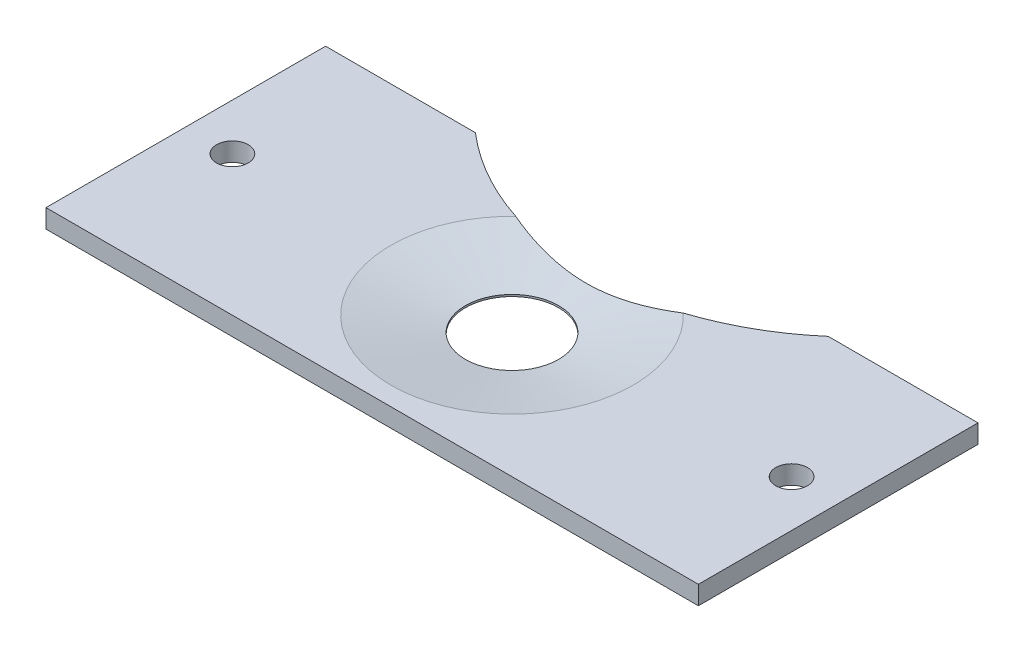
from build123d import *

# Parameters (mm, degrees)
SKETCH1_W            = 70
SKETCH1_H            = 30
SKETCH1_R            = 5
EXTRUDE1_DEPTH       = 2
CHAMFER1_SIZE        = 8
CHAMFER1_SIZE2       = 1.6
SKETCH3_R            = 5.5
CUT_EXTRUDE1_DEPTH   = 0.2
M3_CLEARANCE_HOLE1_D = 3.4
SKETCH7_R            = 28.969188929
CUT_EXTRUDE2_DEPTH   = 3


with BuildPart() as part:
    # Sketch1 → Extrude1 (new body)
    with BuildSketch(Plane(origin=(0, 0, 0), x_dir=(1, 0, 0), z_dir=(0, 1, 0))):
        Rectangle(SKETCH1_W, SKETCH1_H)
        Circle(SKETCH1_R, mode=Mode.SUBTRACT)
    extrude(amount=EXTRUDE1_DEPTH)

    # Chamfer1
    chamfer1_edges = [part.edges().sort_by_distance(p)[0] for p in [
        (-5, 2, 0),
    ]]
    chamfer1_side = [part.faces().sort_by_distance(p)[0] for p in [
        (0, 2, -14.238422689),
    ]]
    chamfer(chamfer1_edges, length=CHAMFER1_SIZE, length2=CHAMFER1_SIZE2, reference=chamfer1_side[0])

    # Sketch3 → Cut-Extrude1 (cut)
    with BuildSketch(Plane.XZ):
        Circle(SKETCH3_R)
    extrude(amount=-CUT_EXTRUDE1_DEPTH, mode=Mode.SUBTRACT)

    # M3 Clearance Hole1 (through all)
    with Locations(Plane(origin=(0, 2, 0), x_dir=(-1, 0, 0), z_dir=(0, 1, 0))):
        with Locations((-30, 0), (30, 0)):
            Hole(M3_CLEARANCE_HOLE1_D / 2)

    # Sketch7 → Cut-Extrude2 (cut, through all)
    with BuildSketch(Plane(origin=(0, 2, 0), x_dir=(-1, 0, 0), z_dir=(0, 1, 0))):
        with Locations((0, -36.93290324)):
            Circle(SKETCH7_R)
    extrude(amount=-CUT_EXTRUDE2_DEPTH, mode=Mode.SUBTRACT)


solid = part.part
